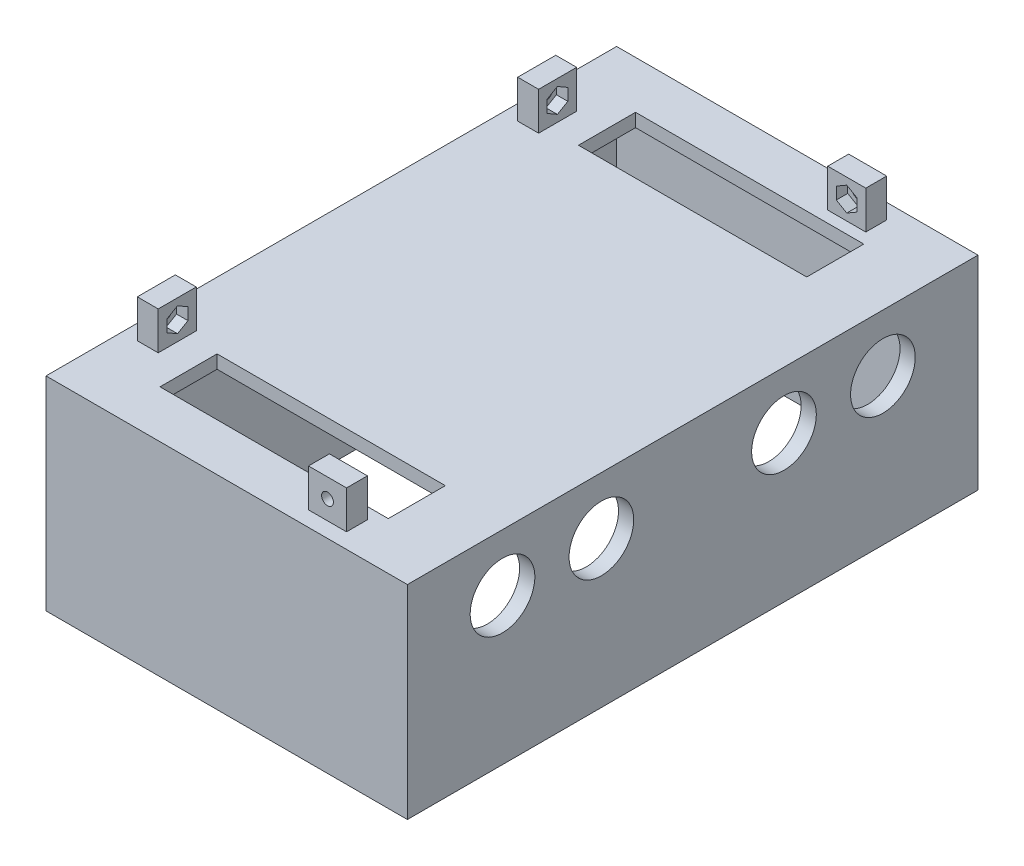
from build123d import *

# Parameters (mm, degrees)
SKETCH1_W           = 95
SKETCH1_H           = 150
BOSS_EXTRUDE1_DEPTH = 3.5
SKETCH2_W           = 5.5
SKETCH2_H           = 10
SKETCH2_W_2         = 10
SKETCH2_H_2         = 5.5
BOSS_EXTRUDE2_DEPTH = 10
CUT_EXTRUDE1_DEPTH  = 3
CUT_EXTRUDE2_DEPTH  = 3
SKETCH6_R           = 1.55
CUT_EXTRUDE3_DEPTH  = 10.5
SKETCH7_R           = 1.55
CUT_EXTRUDE4_DEPTH  = 10.5
SKETCH8_W           = 95
SKETCH8_H           = 150
SKETCH8_W_2         = 87
SKETCH8_H_2         = 142
BOSS_EXTRUDE3_DEPTH = 50
SKETCH9_W           = 60
SKETCH9_H           = 15
CUT_EXTRUDE5_DEPTH  = 50
SKETCH10_R          = 8.5
CUT_EXTRUDE6_DEPTH  = 50


with BuildPart() as part:
    # Sketch1 → Boss-Extrude1 (new body)
    with BuildSketch(Plane(origin=(0, 0, 0), x_dir=(1, 0, 0), z_dir=(0, 1, 0))):
        Rectangle(SKETCH1_W, SKETCH1_H)
    extrude(amount=BOSS_EXTRUDE1_DEPTH)

    # Sketch2 → Boss-Extrude2 (add)
    with BuildSketch(Plane(origin=(0, 3.5, 0), x_dir=(1, 0, 0), z_dir=(0, 1, 0))):
        with Locations((-40.75, 50)):
            Rectangle(SKETCH2_W, SKETCH2_H)
        with Locations((22.5, 68.25)):
            Rectangle(SKETCH2_W_2, SKETCH2_H_2)
    boss_extrude2 = extrude(amount=BOSS_EXTRUDE2_DEPTH)

    # Sketch3 → Cut-Extrude1 (cut)
    with BuildSketch(Plane.XY.offset(-65.5)):
        Polygon((22.5, 5.324573519), (25.25, 6.91228676), (25.25, 10.08771324), (22.5, 11.675426481), (19.75, 10.08771324), (19.75, 6.91228676), align=None)
    cut_extrude1 = extrude(amount=-CUT_EXTRUDE1_DEPTH, mode=Mode.SUBTRACT)

    # Sketch4 → Cut-Extrude2 (cut)
    with BuildSketch(Plane(origin=(-38, 0, 0), x_dir=(0, 0, -1), z_dir=(1, 0, 0))):
        Polygon((49.928125047, 5.324573519), (52.678125047, 6.91228676), (52.678125047, 10.08771324), (49.928125047, 11.675426481), (47.178125047, 10.08771324), (47.178125047, 6.91228676), align=None)
    cut_extrude2 = extrude(amount=-CUT_EXTRUDE2_DEPTH, mode=Mode.SUBTRACT)

    # Sketch6 → Cut-Extrude3 (cut, through all)
    with BuildSketch(Plane(origin=(-38, 0, 0), x_dir=(0, 0, -1), z_dir=(1, 0, 0))):
        with Locations((50, 8.5)):
            Circle(SKETCH6_R)
    cut_extrude3 = extrude(amount=-CUT_EXTRUDE3_DEPTH, mode=Mode.SUBTRACT)

    # Sketch7 → Cut-Extrude4 (cut, through all)
    with BuildSketch(Plane.XY.offset(-65.5)):
        with Locations((22.5, 8.5)):
            Circle(SKETCH7_R)
    cut_extrude4 = extrude(amount=-CUT_EXTRUDE4_DEPTH, mode=Mode.SUBTRACT)

    # Sketch8 → Boss-Extrude3 (add)
    with BuildSketch(Plane.XZ):
        Rectangle(SKETCH8_W, SKETCH8_H)
        Rectangle(SKETCH8_W_2, SKETCH8_H_2, mode=Mode.SUBTRACT)
    extrude(amount=BOSS_EXTRUDE3_DEPTH)

    # Sketch9 → Cut-Extrude5 (cut)
    with BuildSketch(Plane.XZ):
        with Locations((-0.026887888, -55)):
            Rectangle(SKETCH9_W, SKETCH9_H)
    cut_extrude5 = extrude(amount=-CUT_EXTRUDE5_DEPTH, mode=Mode.SUBTRACT)

    # Sketch10 → Cut-Extrude6 (cut)
    with BuildSketch(Plane(origin=(47.5, 0, 0), x_dir=(0, 0, -1), z_dir=(1, 0, 0))):
        with Locations((50, -11.5)):
            Circle(SKETCH10_R)
        with Locations((24, -11.5)):
            Circle(SKETCH10_R)
    cut_extrude6 = extrude(amount=-CUT_EXTRUDE6_DEPTH, mode=Mode.SUBTRACT)

    # Mirror1: Boss-Extrude2, Cut-Extrude1, Cut-Extrude2, Cut-Extrude3, Cut-Extrude4, Cut-Extrude5, Cut-Extrude6 across plane
    add(boss_extrude2.mirror(Plane.XY))
    add(cut_extrude1.mirror(Plane.XY), mode=Mode.SUBTRACT)
    add(cut_extrude2.mirror(Plane.XY), mode=Mode.SUBTRACT)
    add(cut_extrude3.mirror(Plane.XY), mode=Mode.SUBTRACT)
    add(cut_extrude4.mirror(Plane.XY), mode=Mode.SUBTRACT)
    add(cut_extrude5.mirror(Plane.XY), mode=Mode.SUBTRACT)
    add(cut_extrude6.mirror(Plane.XY), mode=Mode.SUBTRACT)


solid = part.part
